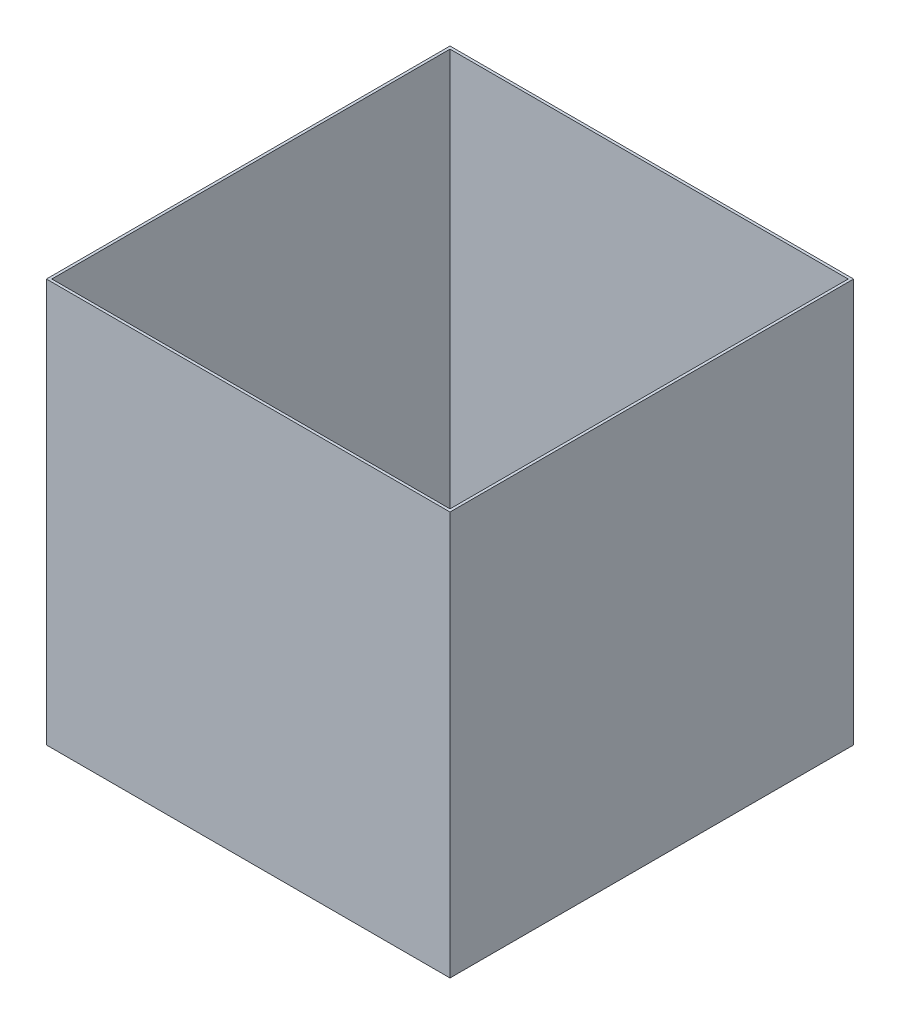
from build123d import *

# Parameters (mm, degrees)
SKETCH1_W           = 300
SKETCH1_H           = 300
BOSS_EXTRUDE1_DEPTH = 300
SHELL1_T            = -2


with BuildPart() as part:
    # Sketch1 → Boss-Extrude1 (new body)
    with BuildSketch(Plane(origin=(0, 0, 0), x_dir=(1, 0, 0), z_dir=(0, 1, 0))):
        Rectangle(SKETCH1_W, SKETCH1_H)
    extrude(amount=BOSS_EXTRUDE1_DEPTH)

    # Shell1
    shell1_openings = [part.faces().sort_by_distance(p)[0] for p in [
        (0, 300, 0),
    ]]
    offset(amount=SHELL1_T, openings=shell1_openings, kind=Kind.INTERSECTION)


solid = part.part
